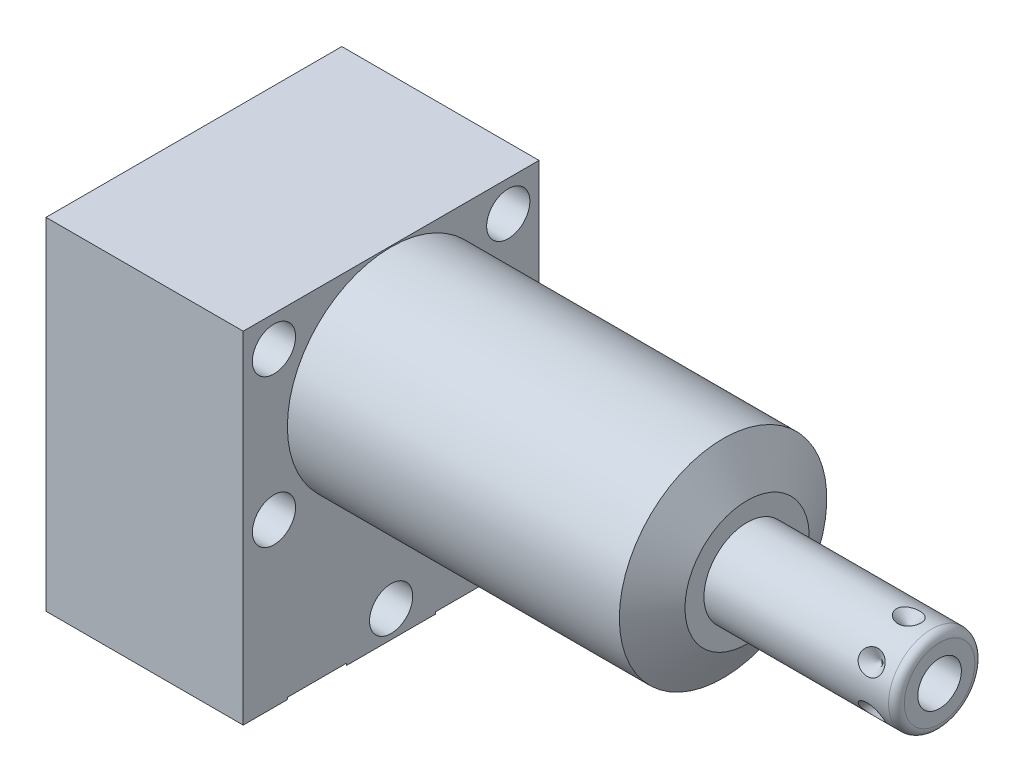
from build123d import *

# Parameters (mm, degrees)
SKETCH1_W           = 38.1
SKETCH1_H           = 43.942
EXTRUDE1_DEPTH      = 45.847
EXTRUDE1_DEPTH_BACK = 25.4
CUT_EXTRUDE1_REACH  = 47.847
SKETCH2_W           = 38.1
SKETCH2_H           = 43.942
SKETCH2_R           = 13.3604
SKETCH14_R          = 7.9375
CUT_EXTRUDE2_DEPTH  = 2.667
CIRPATTERN1_COUNT   = 6
HOLE1_D             = 5.5626
HOLE1_DEPTH         = 25.4
SKETCH18_R          = 1.7653


with BuildPart() as part:
    # Sketch1 → Extrude1 (new body, two sides)
    with BuildSketch(Plane(origin=(0, 0, 0), x_dir=(0, 0, -1), z_dir=(1, 0, 0))) as extrude1_sk:
        with Locations((0, -8.4836)):
            Rectangle(SKETCH1_W, SKETCH1_H)
    extrude(amount=EXTRUDE1_DEPTH)
    extrude(extrude1_sk.sketch, amount=-EXTRUDE1_DEPTH_BACK)

    # Sketch2 → Cut-Extrude1 (cut, up to next)
    with BuildSketch(Plane(origin=(0, 0, 0), x_dir=(0, 0, -1), z_dir=(1, 0, 0)), mode=Mode.PRIVATE) as cut_extrude1_sk1:
        with Locations((0, -8.4836)):
            Rectangle(SKETCH2_W, SKETCH2_H)
        Circle(SKETCH2_R, mode=Mode.SUBTRACT)
    cut_extrude1_tool1 = extrude(cut_extrude1_sk1.sketch, amount=CUT_EXTRUDE1_REACH, mode=Mode.PRIVATE) & part.part
    add(cut_extrude1_tool1.solids().sort_by_distance((0, 13.429241, 0))[0], mode=Mode.SUBTRACT)

    # Sketch3 → Cut-Revolve1 (revolve, cut)
    with BuildSketch(Plane.XY, mode=Mode.PRIVATE) as cut_revolve1_sk:
        Polygon((42.752748967, 13.3604), (45.847, 8.001), (45.847, 13.3604), align=None)
    revolve(cut_revolve1_sk.sketch.rotate(Axis((42.598036416, 0, 0), (1, 0, 0)), 90), axis=Axis((42.598036416, 0, 0), (1, 0, 0)), mode=Mode.SUBTRACT)  # turned: the seam where the file's is

    # S2D0002 → Cut-Revolve2 (revolve, cut)
    with BuildSketch(Plane(origin=(-22.733, -19.8374, 9.525), x_dir=(0, 1, 0), z_dir=(0, 0, 1)), mode=Mode.PRIVATE) as cut_revolve2_sk:
        Polygon((-0.8128, 0), (3.7338, 0), (3.293786662, -2.0701), (2.6416, -2.722286662), (2.6416, -13.97), (-0.8128, -13.97), align=None)
    revolve(cut_revolve2_sk.sketch.rotate(Axis((-8.0645, -20.6502, 9.525), (-1, 0, 0)), 90), axis=Axis((-8.0645, -20.6502, 9.525), (-1, 0, 0)), mode=Mode.SUBTRACT)  # turned: the seam where the file's is

    # Sketch5 → Cut-Revolve3 (revolve, cut)
    with BuildSketch(Plane(origin=(-22.733, -19.8374, -9.525), x_dir=(0, 1, 0), z_dir=(0, 0, 1)), mode=Mode.PRIVATE) as cut_revolve3_sk:
        Polygon((-0.8128, 0), (3.7338, 0), (3.293786662, -2.0701), (2.6416, -2.722286662), (2.6416, -13.97), (-0.8128, -13.97), align=None)
    revolve(cut_revolve3_sk.sketch.rotate(Axis((-8.0645, -20.6502, -9.525), (-1, 0, 0)), 90), axis=Axis((-8.0645, -20.6502, -9.525), (-1, 0, 0)), mode=Mode.SUBTRACT)  # turned: the seam where the file's is

    # Sketch14 → Cut-Extrude2 (cut)
    with BuildSketch(Plane.ZY.offset(25.4)):
        with Locations((-9.525, -20.6502)):
            Circle(SKETCH14_R)
        with Locations((9.525, -20.6502)):
            Circle(SKETCH14_R)
    extrude(amount=-CUT_EXTRUDE2_DEPTH, mode=Mode.SUBTRACT)

    # Sketch6 → Cut-Revolve4 (revolve, cut)
    with BuildSketch(Plane(origin=(-8.7376, -30.2006, 9.525), x_dir=(-1, 0, 0), z_dir=(0, 0, 1)), mode=Mode.PRIVATE) as cut_revolve4_sk:
        Polygon((6.18363, 0), (5.641036865, -2.5527), (4.97713, -3.216606865), (4.97713, -17.272), (0, -17.272), (0, 0), (0, 0.254), (9.52373, 0.254), (9.52373, 0), align=None)
    revolve(cut_revolve4_sk.sketch.rotate(Axis((-8.7376, -12.065, 9.525), (0, -1, 0)), 270), axis=Axis((-8.7376, -12.065, 9.525), (0, -1, 0)), mode=Mode.SUBTRACT)  # turned: the seam where the file's is

    # Sketch7 → Cut-Revolve5 (revolve, cut)
    with BuildSketch(Plane(origin=(-8.7376, -30.2006, -9.525), x_dir=(-1, 0, 0), z_dir=(0, 0, 1)), mode=Mode.PRIVATE) as cut_revolve5_sk:
        Polygon((6.1849, 0), (5.642306865, -2.5527), (4.9784, -3.216606865), (4.9784, -17.272), (0, -17.272), (0, 0), (0, 0.254), (9.52373, 0.254), (9.52373, 0), align=None)
    revolve(cut_revolve5_sk.sketch.rotate(Axis((-8.7376, -12.065, -9.525), (0, -1, 0)), 270), axis=Axis((-8.7376, -12.065, -9.525), (0, -1, 0)), mode=Mode.SUBTRACT)  # turned: the seam where the file's is

    # Sketch8 → Revolve1 (revolve)
    with BuildSketch(Plane.XY, mode=Mode.PRIVATE) as revolve1_sk:
        with BuildLine():
            Line((45.847, 0), (45.847, 5.55625))
            Line((45.847, 5.55625), (69.6214, 5.55625))
            ThreePointArc((69.6214, 5.55625), (70.33982049, 5.25867049), (70.6374, 4.54025))
            Line((70.6374, 4.54025), (70.6374, 0))
            Line((70.6374, 0), (45.847, 0))
        make_face()
    revolve(revolve1_sk.sketch.rotate(Axis((44.83227, 0, 0), (1, 0, 0)), 90), axis=Axis((44.83227, 0, 0), (1, 0, 0)))  # turned: the seam where the file's is

    # S2D0001 → Cut-Revolve6 (revolve, cut)
    with BuildSketch(Plane(origin=(66.1416, -2.8067, 0), x_dir=(0, -1, 0), z_dir=(0, 0, 1)), mode=Mode.PRIVATE) as cut_revolve6_sk:
        Polygon((0, 4.4958), (0, -5.6642), (-2.8067, -7.350635499), (-2.8067, 4.4958), align=None)
    revolve(cut_revolve6_sk.sketch.rotate(Axis((53.702842726, 0, 0), (1, 0, 0)), 270), axis=Axis((53.702842726, 0, 0), (1, 0, 0)), mode=Mode.SUBTRACT)  # turned: the seam where the file's is

    # Sketch12 → Cut-Revolve7 (revolve, cut)
    with BuildSketch(Plane(origin=(62.1792, -5.55625, 0), x_dir=(-1, 0, 0), z_dir=(0, 0, 1)), mode=Mode.PRIVATE) as cut_revolve7_sk:
        Polygon((-4.4958, 0), (-2.9083, 0), (-4.4958, -1.5875), align=None)
    cut_revolve7 = revolve(cut_revolve7_sk.sketch.rotate(Axis((66.675, -2.12229387, 0), (0, -1, 0)), 90), axis=Axis((66.675, -2.12229387, 0), (0, -1, 0)), mode=Mode.SUBTRACT)  # turned: the seam where the file's is

    # CirPattern1: Cut-Revolve7 ×6 about axis
    cirpattern1_axis = Axis((45.848, 0, 0), (-1, 0, 0))
    for i in range(1, CIRPATTERN1_COUNT):
        add(cut_revolve7.rotate(cirpattern1_axis, i * 360 / CIRPATTERN1_COUNT), mode=Mode.SUBTRACT)

    # Hole1
    with Locations(Plane(origin=(0, 0, 0), x_dir=(0, 0, -1), z_dir=(1, 0, 0))):
        with Locations((-15.0876, 9.525), (-15.0876, -9.525), (15.0876, 9.525), (15.0876, -9.525), (0, -26.9748)):
            Hole(HOLE1_D / 2, depth=HOLE1_DEPTH)


with BuildPart() as body_2:
    # Sketch18 → Revolve2 (revolve)
    with BuildSketch(Plane(origin=(-8.7376, -30.2006, 9.525), x_dir=(-1, 0, 0), z_dir=(0, 0, 1)), mode=Mode.PRIVATE) as revolve2_sk:
        with Locations((15.7607, -3.3782)):
            Circle(SKETCH18_R)
    revolve(revolve2_sk.sketch.rotate(Axis((-8.099075598, -20.6502, 9.525), (-1, 0, 0)), 90), axis=Axis((-8.099075598, -20.6502, 9.525), (-1, 0, 0)))  # turned: the seam where the file's is


solid = Compound([part.part, body_2.part])
